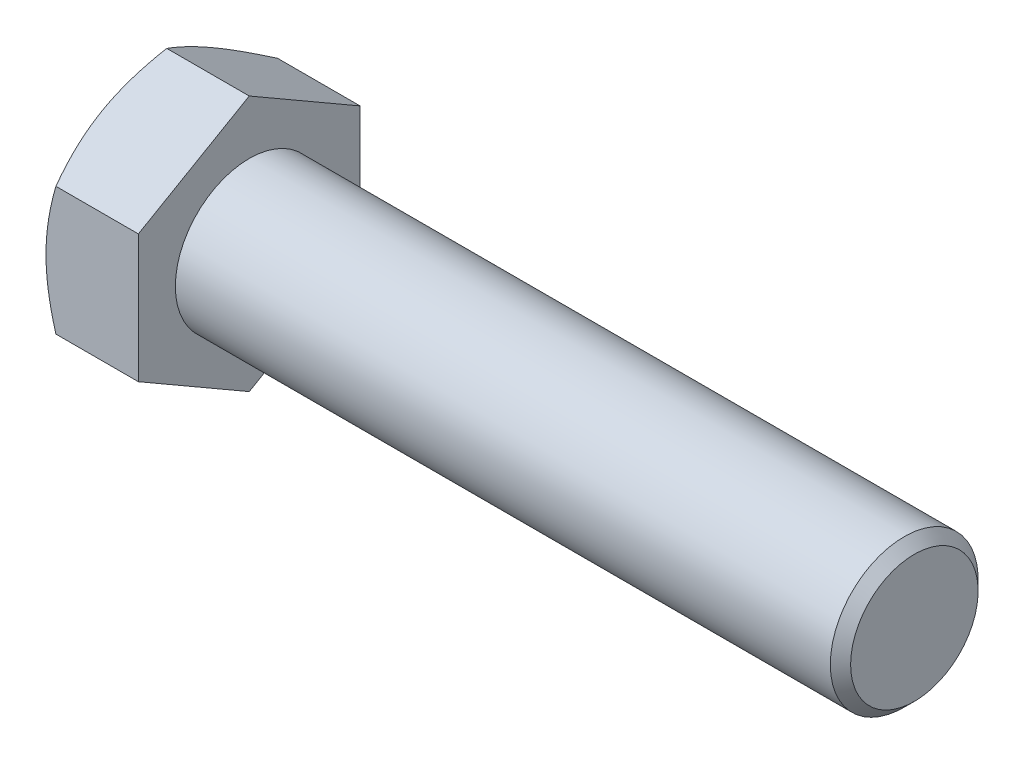
from build123d import *

# Parameters (mm, degrees)
BASEHEAD_DEPTH = 12.5


with BuildPart() as part:
    # Sketch1 → BaseHead (new body)
    with BuildSketch(Plane(origin=(0, 0, 0), x_dir=(0, 0, -1), z_dir=(1, 0, 0))):
        Polygon((15, 8.660254038), (15, -8.660254038), (0, -17.320508076), (-15, -8.660254038), (-15, 8.660254038), (0, 17.320508076), align=None)
    extrude(amount=BASEHEAD_DEPTH)

    # BodySke → BaseBody (revolve)
    with BuildSketch(Plane.XY):
        Polygon((0, 0), (102.5, 0), (102.5, 8.626), (101.126, 10), (0, 10), align=None)
    revolve(axis=Axis((0, 0, 0), (1, 0, 0)))

    # Sketch3 → HeadChamfer (revolve, cut)
    with BuildSketch(Plane.XY):
        Polygon((0, 15), (4.226497308, 22.320508076), (4.226497308, 27.320508076), (-10, 27.320508076), (-10, 15), align=None)
    revolve(axis=Axis((0, 0, 0), (1, 0, 0)), mode=Mode.SUBTRACT)


solid = part.part
